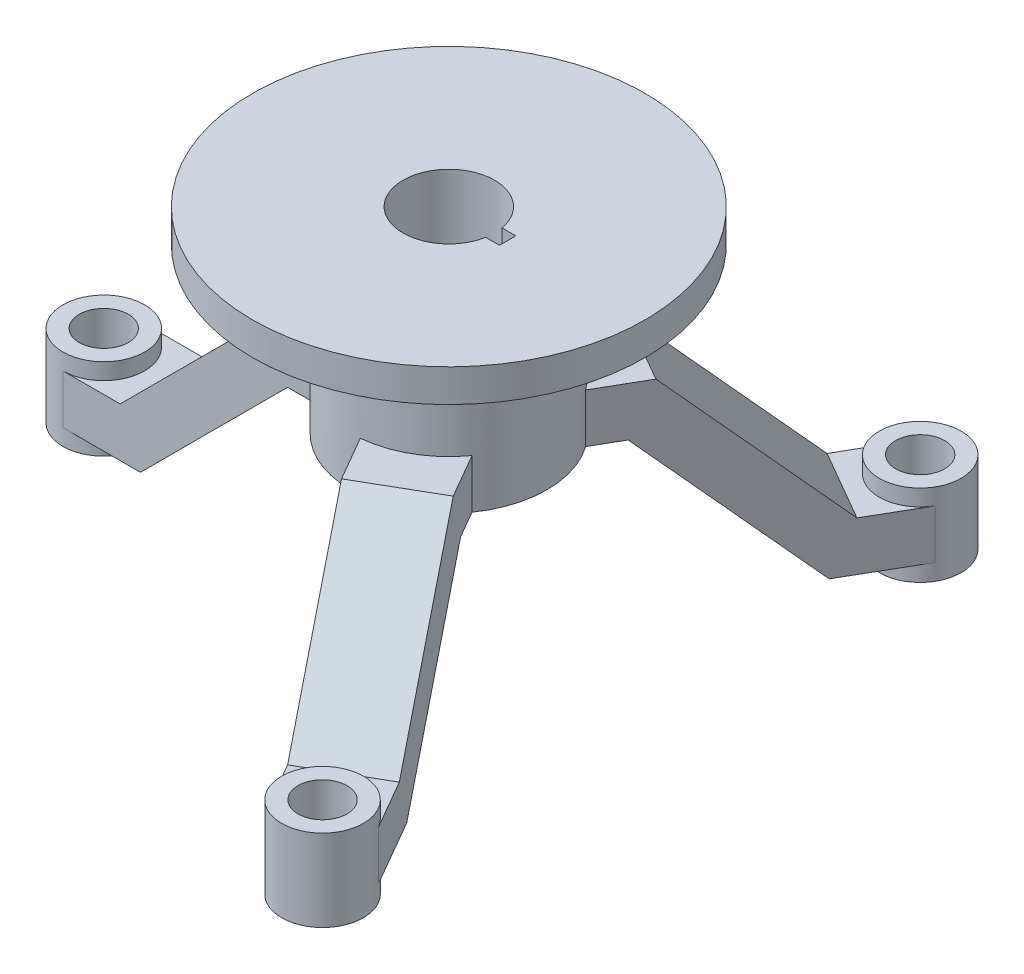
from build123d import *

# Parameters (mm, degrees)
SKETCH1_R           = 120
BOSS_EXTRUDE1_DEPTH = 20
SKETCH2_R           = 60
BOSS_EXTRUDE2_DEPTH = 100
CUT_EXTRUDE1_DEPTH  = 121
BOSS_EXTRUDE3_DEPTH = 25
BOSS_EXTRUDE4_START = -40
SKETCH5_R           = 25
BOSS_EXTRUDE4_DEPTH = 50
SKETCH6_R           = 15
CUT_EXTRUDE2_DEPTH  = 51
CIRPATTERN1_COUNT   = 3
FILLET2_R           = 10


with BuildPart() as part:
    # Sketch1 → Boss-Extrude1 (new body)
    with BuildSketch(Plane(origin=(0, 0, 0), x_dir=(1, 0, 0), z_dir=(0, 1, 0))):
        with Locations(Location((0, 0, 0), (0, 0, 270))):  # turned: the seam where the file's is
            Circle(SKETCH1_R)
    extrude(amount=BOSS_EXTRUDE1_DEPTH)

    # Sketch2 → Boss-Extrude2 (add)
    with BuildSketch(Plane.XZ):
        with Locations(Location((0, 0, 0), (0, 0, 270))):  # turned: the seam where the file's is
            Circle(SKETCH2_R)
    extrude(amount=BOSS_EXTRUDE2_DEPTH)

    # Sketch3 → Cut-Extrude1 (cut, through all)
    with BuildSketch(Plane(origin=(0, 20, 0), x_dir=(1, 0, 0), z_dir=(0, 1, 0))):
        with BuildLine():
            Line((27.549954628, 5), (36, 5))
            Line((36, 5), (36, -5))
            Line((36, -5), (27.549954628, -5))
            ThreePointArc((27.549954628, -5), (-28, 0), (27.549954628, 5))
        make_face()
    extrude(amount=-CUT_EXTRUDE1_DEPTH, mode=Mode.SUBTRACT)

    # Sketch4 → Boss-Extrude3 (add, symmetric)
    with BuildSketch(Plane.XY):
        Polygon((-45.582672643, -70), (-86, -70), (-176, -160), (-211, -160), (-211, -190), (-163.573593129, -190), (-73.573593129, -100), (-45.582672643, -100), align=None)
    boss_extrude3 = extrude(amount=BOSS_EXTRUDE3_DEPTH, both=True)

    # Sketch5 → Boss-Extrude4 (add)
    with BuildSketch(Plane(origin=(0, -160, 0), x_dir=(1, 0, 0), z_dir=(0, 1, 0)).offset(BOSS_EXTRUDE4_START)):
        with Locations(Location((-211, 0, 0), (0, 0, 270))):  # turned: the seam where the file's is
            Circle(SKETCH5_R)
    boss_extrude4 = extrude(amount=BOSS_EXTRUDE4_DEPTH)

    # Sketch6 → Cut-Extrude2 (cut, through all)
    with BuildSketch(Plane(origin=(0, -150, 0), x_dir=(1, 0, 0), z_dir=(0, 1, 0))):
        with Locations(Location((-211, 0, 0), (0, 0, 270))):  # turned: the seam where the file's is
            Circle(SKETCH6_R)
    cut_extrude2 = extrude(amount=-CUT_EXTRUDE2_DEPTH, mode=Mode.SUBTRACT)

    # CirPattern1: Boss-Extrude3, Boss-Extrude4, Cut-Extrude2 ×3 about axis
    cirpattern1_axis = Axis((0, 0, 0), (0, 1, 0))
    add([boss_extrude3.rotate(cirpattern1_axis, i * 360 / CIRPATTERN1_COUNT) for i in range(1, CIRPATTERN1_COUNT)])
    add([boss_extrude4.rotate(cirpattern1_axis, i * 360 / CIRPATTERN1_COUNT) for i in range(1, CIRPATTERN1_COUNT)])
    add([cut_extrude2.rotate(cirpattern1_axis, i * 360 / CIRPATTERN1_COUNT) for i in range(1, CIRPATTERN1_COUNT)], mode=Mode.SUBTRACT)

    # Fillet2
    fillet2_edges = [part.edges().sort_by_distance(p)[0] for p in [
        (0, 0, 60),
    ]]
    fillet(fillet2_edges, radius=FILLET2_R)


solid = part.part
